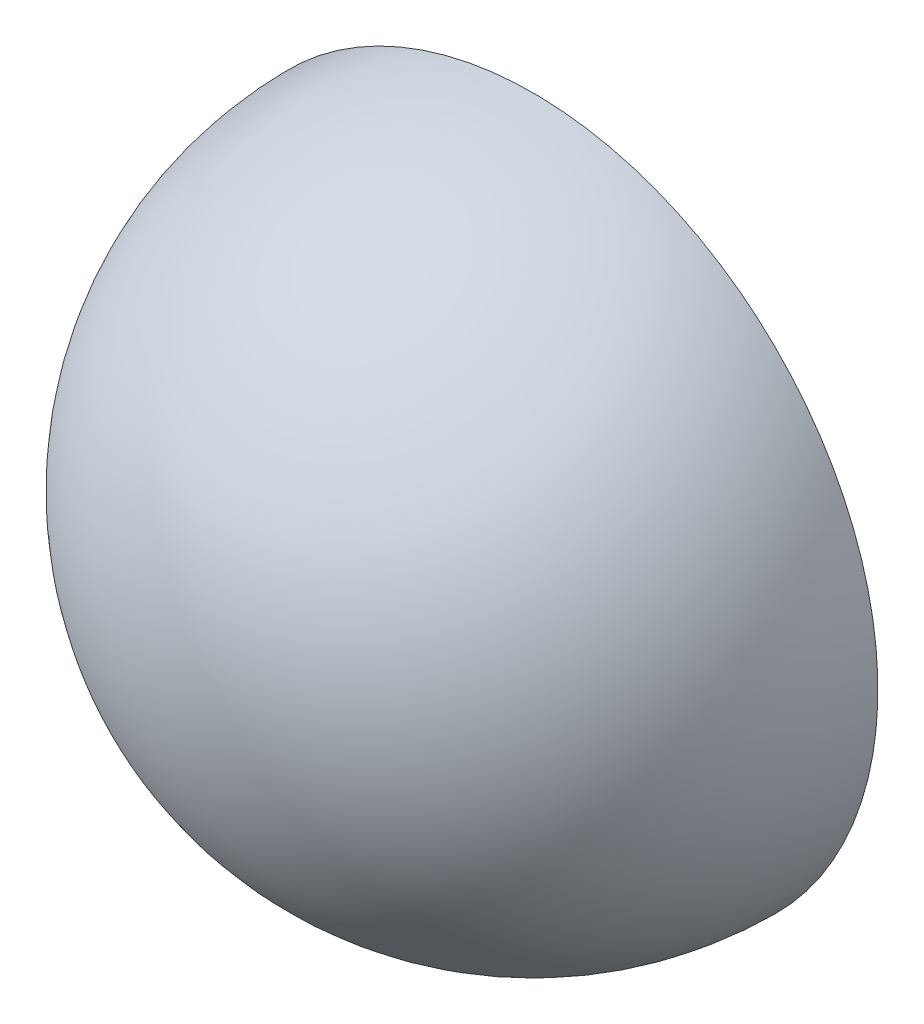
from build123d import *

# Parameters (mm, degrees)
REVOLVE1_ANGLE = 180


with BuildPart() as part:
    # Sketch1 → Revolve1 (revolve)
    with BuildSketch(Plane.XY):
        with BuildLine():
            Line((0, 5), (0, -5))
            ThreePointArc((0, -5), (5, 0), (0, 5))
        make_face()
    revolve(axis=Axis((0, 5, 0), (0, -1, 0)), revolution_arc=REVOLVE1_ANGLE)


solid = part.part
